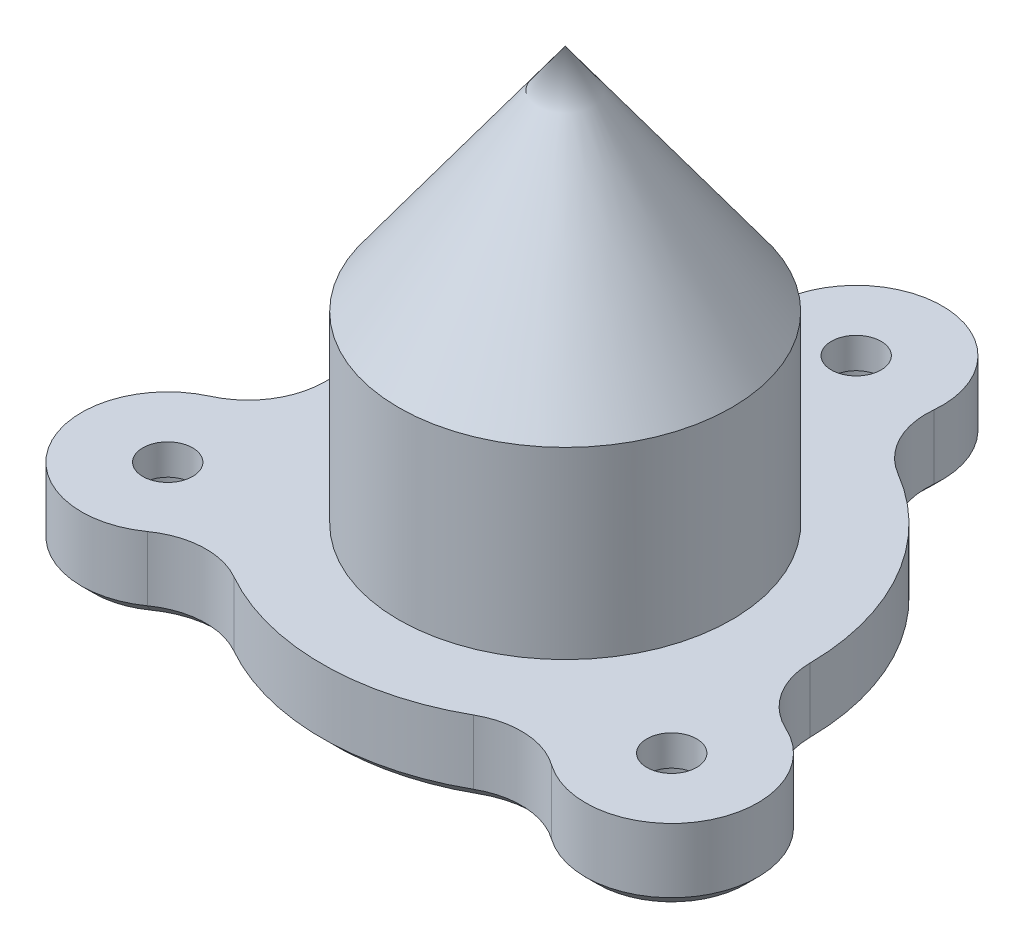
from build123d import *

# Parameters (mm, degrees)
SKETCH1_R           = 10.875
SKETCH1_R_2         = 1.625
BOSS_EXTRUDE1_DEPTH = 5
SKETCH1_2_R         = 10.875
BOSS_EXTRUDE2_DEPTH = 17
CHAMFER1_SIZE       = 0.8
SKETCH3_R           = 2.875
CUT_EXTRUDE1_DEPTH  = 3
CHAMFER2_SIZE       = 0.4


with BuildPart() as part:
    # Sketch1 → Boss-Extrude1 (new body)
    with BuildSketch(Plane(origin=(0, 0, 0), x_dir=(1, 0, 0), z_dir=(0, 1, 0))):
        with BuildLine():
            ThreePointArc((5.599866179, 18.468846749), (0, 24.625), (-5.599866179, 18.468846749))
            ThreePointArc((-5.599866179, 18.468846749), (-6.125206634, 15.721438867), (-8.043986082, 13.686121179))
            ThreePointArc((-8.043986082, 13.686121179), (-13.748153285, 7.9375), (-15.874521661, 0.123235705))
            ThreePointArc((-15.874521661, 0.123235705), (-16.67776876, -2.556134885), (-18.794423553, -4.384797006))
            ThreePointArc((-18.794423553, -4.384797006), (-21.325875568, -12.3125), (-13.194557374, -14.084049744))
            ThreePointArc((-13.194557374, -14.084049744), (-10.552562126, -13.165303982), (-7.830535579, -13.809356884))
            ThreePointArc((-7.830535579, -13.809356884), (0, -15.875), (7.830535579, -13.809356884))
            ThreePointArc((7.830535579, -13.809356884), (10.552562126, -13.165303982), (13.194557374, -14.084049744))
            ThreePointArc((13.194557374, -14.084049744), (21.325875568, -12.3125), (18.794423553, -4.384797006))
            ThreePointArc((18.794423553, -4.384797006), (16.67776876, -2.556134885), (15.874521661, 0.123235705))
            ThreePointArc((15.874521661, 0.123235705), (13.748153285, 7.9375), (8.043986082, 13.686121179))
            ThreePointArc((8.043986082, 13.686121179), (6.125206634, 15.721438867), (5.599866179, 18.468846749))
        make_face()
        Circle(SKETCH1_R, mode=Mode.SUBTRACT)
        with Locations((0, 19)):
            Circle(SKETCH1_R_2, mode=Mode.SUBTRACT)
        with Locations((16.454482672, -9.5)):
            Circle(SKETCH1_R_2, mode=Mode.SUBTRACT)
        with Locations((-16.454482672, -9.5)):
            Circle(SKETCH1_R_2, mode=Mode.SUBTRACT)
    extrude(amount=BOSS_EXTRUDE1_DEPTH)

    # Sketch1_2 → Boss-Extrude2 (add)
    with BuildSketch(Plane(origin=(0, 0, 0), x_dir=(1, 0, 0), z_dir=(0, 1, 0))):
        Circle(SKETCH1_2_R)
    extrude(amount=BOSS_EXTRUDE2_DEPTH)

    # Sketch2 → Revolve1 (revolve)
    with BuildSketch(Plane.XY):
        Polygon((0, 17), (10.875, 17), (0, 32), align=None)
    revolve(axis=Axis((0, 18.413549721, 0), (0, -1, 0)))

    # Chamfer1
    chamfer1_edges = [part.edges().sort_by_distance(p)[0] for p in [
        (0, 0, -24.625),
        (-6.125206634, 0, -15.721438867),
        (6.125206634, 0, -15.721438867),
        (-13.748153285, 0, -7.9375),
        (13.748153285, 0, -7.9375),
        (-16.67776876, 0, 2.556134885),
        (16.67776876, 0, 2.556134885),
        (-21.325875568, 0, 12.3125),
        (21.325875568, 0, 12.3125),
        (-10.552562126, 0, 13.165303982),
        (10.552562126, 0, 13.165303982),
        (0, 0, 15.875),
    ]]
    chamfer(chamfer1_edges, length=CHAMFER1_SIZE)

    # Sketch3 → Cut-Extrude1 (cut)
    with BuildSketch(Plane.XZ):
        with Locations((0, -19)):
            Circle(SKETCH3_R)
        with Locations((-16.454482672, 9.5)):
            Circle(SKETCH3_R)
        with Locations((16.454482672, 9.5)):
            Circle(SKETCH3_R)
    extrude(amount=-CUT_EXTRUDE1_DEPTH, mode=Mode.SUBTRACT)

    # Chamfer2
    chamfer2_edges = [part.edges().sort_by_distance(p)[0] for p in [
        (-2.875, 0, -19),
        (13.579482672, 0, 9.5),
        (-19.329482672, 0, 9.5),
    ]]
    chamfer(chamfer2_edges, length=CHAMFER2_SIZE)


solid = part.part
